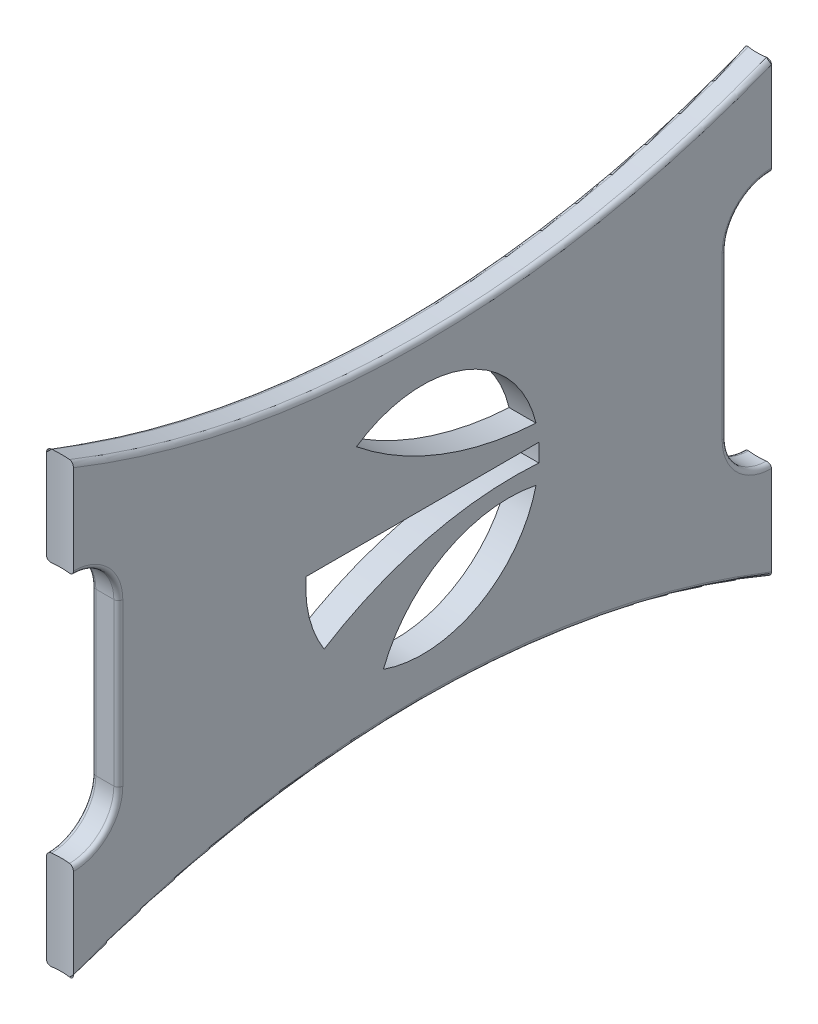
from build123d import *

# Parameters (mm, degrees)
EXTRUSION1_DEPTH        = 25
ENL_V_MAT_EXTRU_1_DEPTH = 4
ENL_V_MAT_EXTRU_2_DEPTH = 4.0000001
CONG_1_R                = 0.5


with BuildPart() as part:
    # Esquisse1 → Extrusion1 (new body, symmetric)
    with BuildSketch(Plane(origin=(0, 0, 0), x_dir=(1, 0, 0), z_dir=(0, 1, 0))):
        with BuildLine():
            Line((-1.5, 38.883399735), (-1.5, -38.883399735))
            ThreePointArc((-1.5, -38.883399735), (0, -38.75), (1.5, -38.883399735))
            Line((1.5, -38.883399735), (1.5, 38.883399735))
            ThreePointArc((1.5, 38.883399735), (0, 38.75), (-1.5, 38.883399735))
        make_face()
    extrude(amount=EXTRUSION1_DEPTH, both=True)

    # Esquisse2 → Enlèv. mat.-Extru.1 (cut, through all)
    with BuildSketch(Plane(origin=(1.5, 0, 0), x_dir=(0, 0, -1), z_dir=(1, 0, 0))):
        with BuildLine():
            Line((-33.883399735, 9), (-33.883399735, -9))
            ThreePointArc((-33.883399735, -9), (-35.347865829, -12.535533906), (-38.883399735, -14))
            Line((-38.883399735, -14), (-38.883399735, 14))
            ThreePointArc((-38.883399735, 14), (-35.347865829, 12.535533906), (-33.883399735, 9))
        make_face()
        with BuildLine():
            Line((38.883399735, 14), (38.883399735, -14))
            ThreePointArc((38.883399735, -14), (35.347865829, -12.535533906), (33.883399735, -9))
            Line((33.883399735, -9), (33.883399735, 9))
            ThreePointArc((33.883399735, 9), (35.347865829, 12.535533906), (38.883399735, 14))
        make_face()
        with BuildLine():
            Line((-38.883399735, 25), (38.883399735, 25))
            ThreePointArc((38.883399735, 25), (0, 17.5), (-38.883399735, 25))
        make_face()
        with BuildLine():
            Line((-38.883399735, -25), (38.883399735, -25))
            ThreePointArc((38.883399735, -25), (0, -17.5), (-38.883399735, -25))
        make_face()
    extrude(amount=-ENL_V_MAT_EXTRU_1_DEPTH, mode=Mode.SUBTRACT)

    # Esquisse3 → Enlèv. mat.-Extru.2 (cut, through all)
    with BuildSketch(Plane(origin=(1.5, 0, 0), x_dir=(0, 0, -1), z_dir=(1, 0, 0))):
        with BuildLine():
            Line((12.961481397, 1), (-12.961481397, 1))
            ThreePointArc((-12.961481397, 1), (-12.609240952, -3.163390997), (-10.95445115, -7))
            ThreePointArc((-10.95445115, -7), (0.529660497, -2.111220787), (12.961481397, -1))
            ThreePointArc((12.961481397, -1), (13, 0), (12.961481397, 1))
        make_face()
        with BuildLine():
            ThreePointArc((-7.350889359, 10.722146503), (2.043285167, 5.292013474), (12.649110641, 3))
            ThreePointArc((12.649110641, 3), (4.682485861, 12.127420425), (-7.350889359, 10.722146503))
        make_face()
        with BuildLine():
            ThreePointArc((12.649110641, -3), (2.457687621, -4.516686577), (-4.350889359, -12.250296396))
            ThreePointArc((-4.350889359, -12.250296396), (6.213462397, -11.418970402), (12.649110641, -3))
        make_face()
    extrude(amount=-ENL_V_MAT_EXTRU_2_DEPTH, mode=Mode.SUBTRACT)

    # Congé1
    cong_1_edges = [part.edges().sort_by_distance(p)[0] for p in [
        (-1.5, 17.5, 0),
        (1.5, 17.5, 0),
        (-1.5, -17.5, 0),
        (1.5, -17.5, 0),
        (-1.5, 12.535533906, 35.347865829),
        (-1.5, -12.535533906, 35.347865829),
        (-1.5, 0, 33.883399735),
        (1.5, 12.535533906, 35.347865829),
        (1.5, -12.535533906, 35.347865829),
        (1.5, 0, 33.883399735),
        (-1.5, -12.535533906, -35.347865829),
        (-1.5, 12.535533906, -35.347865829),
        (-1.5, 0, -33.883399735),
        (1.5, -12.535533906, -35.347865829),
        (1.5, 12.535533906, -35.347865829),
        (1.5, 0, -33.883399735),
    ]]
    fillet(cong_1_edges, radius=CONG_1_R)


solid = part.part
